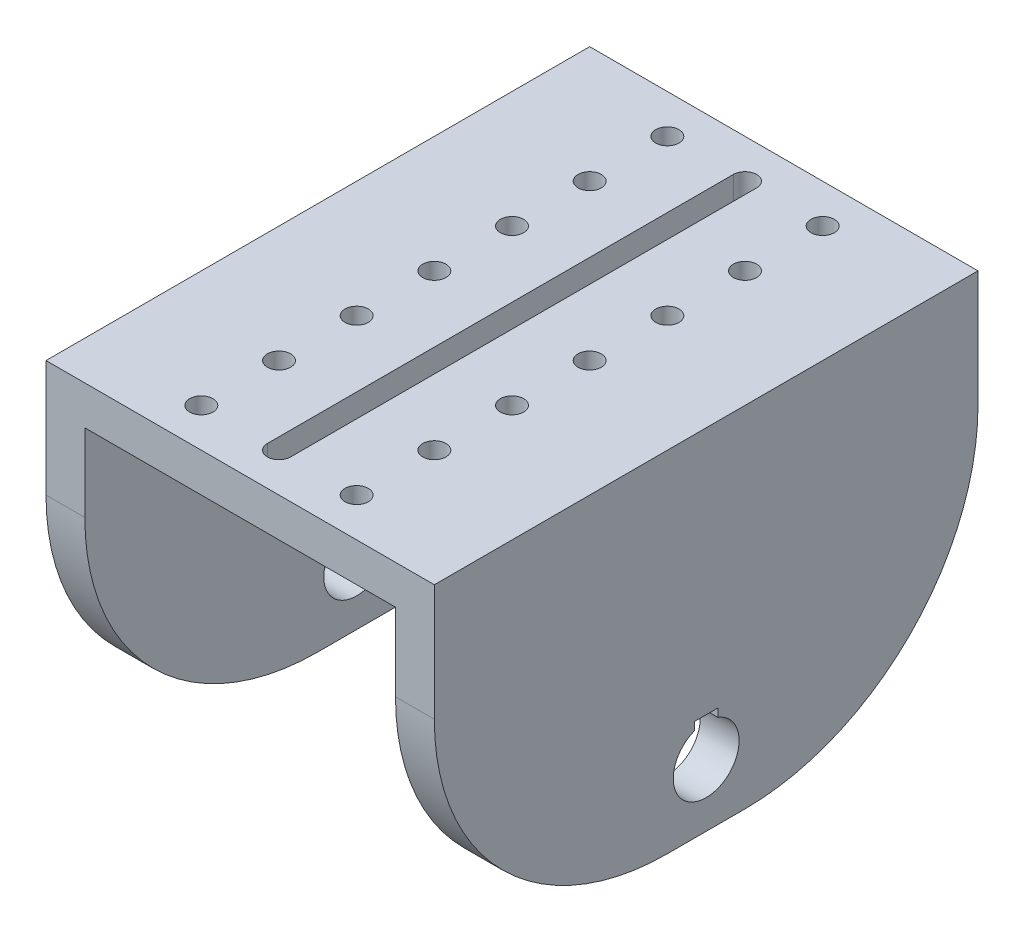
from build123d import *

# Parameters (mm, degrees)
SKETCH1_W           = 50
SKETCH1_H           = 70
SKETCH1_R           = 1.5
BOSS_EXTRUDE1_DEPTH = 5
SKETCH2_W           = 5
SKETCH2_H           = 70
BOSS_EXTRUDE2_DEPTH = 40
FILLET1_R           = 30
CUT_EXTRUDE1_DEPTH  = 51


with BuildPart() as part:
    # Sketch1 → Boss-Extrude1 (new body)
    with BuildSketch(Plane(origin=(0, 0, 0), x_dir=(1, 0, 0), z_dir=(0, 1, 0))):
        with Locations((-195.719432441, 94.934599156)):
            Rectangle(SKETCH1_W, SKETCH1_H)
        with Locations((-185.719432441, 94.934599156)):
            Circle(SKETCH1_R, mode=Mode.SUBTRACT)
        with Locations((-205.719432441, 94.934599156)):
            Circle(SKETCH1_R, mode=Mode.SUBTRACT)
        with Locations((-205.719432441, 104.934599156)):
            Circle(SKETCH1_R, mode=Mode.SUBTRACT)
        with Locations((-185.719432441, 104.934599156)):
            Circle(SKETCH1_R, mode=Mode.SUBTRACT)
        with Locations((-205.719432441, 114.934599156)):
            Circle(SKETCH1_R, mode=Mode.SUBTRACT)
        with Locations((-185.719432441, 114.934599156)):
            Circle(SKETCH1_R, mode=Mode.SUBTRACT)
        with Locations((-205.719432441, 124.934599156)):
            Circle(SKETCH1_R, mode=Mode.SUBTRACT)
        with Locations((-185.719432441, 124.934599156)):
            Circle(SKETCH1_R, mode=Mode.SUBTRACT)
        with Locations((-205.719432441, 84.934599156)):
            Circle(SKETCH1_R, mode=Mode.SUBTRACT)
        with Locations((-185.719432441, 84.934599156)):
            Circle(SKETCH1_R, mode=Mode.SUBTRACT)
        with Locations((-205.719432441, 74.934599156)):
            Circle(SKETCH1_R, mode=Mode.SUBTRACT)
        with Locations((-185.719432441, 74.934599156)):
            Circle(SKETCH1_R, mode=Mode.SUBTRACT)
        with Locations((-205.719432441, 64.934599156)):
            Circle(SKETCH1_R, mode=Mode.SUBTRACT)
        with Locations((-185.719432441, 64.934599156)):
            Circle(SKETCH1_R, mode=Mode.SUBTRACT)
        with BuildLine():
            Line((-197.219432441, 124.934599156), (-197.219432441, 64.934599156))
            ThreePointArc((-197.219432441, 64.934599156), (-195.719432441, 63.434599156), (-194.219432441, 64.934599156))
            Line((-194.219432441, 64.934599156), (-194.219432441, 124.934599156))
            ThreePointArc((-194.219432441, 124.934599156), (-195.719432441, 126.434599156), (-197.219432441, 124.934599156))
        make_face(mode=Mode.SUBTRACT)
    extrude(amount=BOSS_EXTRUDE1_DEPTH)

    # Sketch2 → Boss-Extrude2 (add)
    with BuildSketch(Plane(origin=(0, 0, 0), x_dir=(1, 0, 0), z_dir=(0, 1, 0))):
        with Locations((-218.219432441, 94.934599156)):
            Rectangle(SKETCH2_W, SKETCH2_H)
        with Locations((-173.219432441, 94.934599156)):
            Rectangle(SKETCH2_W, SKETCH2_H)
    extrude(amount=-BOSS_EXTRUDE2_DEPTH)

    # Fillet1
    fillet1_edges = [part.edges().sort_by_distance(p)[0] for p in [
        (-218.219432441, -40, -129.934599156),
        (-218.219432441, -40, -59.934599156),
        (-173.219432441, -40, -59.934599156),
        (-173.219432441, -40, -129.934599156),
    ]]
    fillet(fillet1_edges, radius=FILLET1_R)

    # Sketch3 → Cut-Extrude1 (cut, through all)
    with BuildSketch(Plane(origin=(-170.719432441, 0, 0), x_dir=(0, 0, -1), z_dir=(1, 0, 0))):
        with BuildLine():
            Line((94.934599156, -27), (96.434599156, -27))
            Line((96.434599156, -27), (96.434599156, -28.034196172))
            ThreePointArc((96.434599156, -28.034196172), (94.934599156, -36.24), (93.434599156, -28.034196172))
            Line((93.434599156, -28.034196172), (93.434599156, -27))
            Line((93.434599156, -27), (94.934599156, -27))
        make_face()
    extrude(amount=-CUT_EXTRUDE1_DEPTH, mode=Mode.SUBTRACT)


solid = part.part
